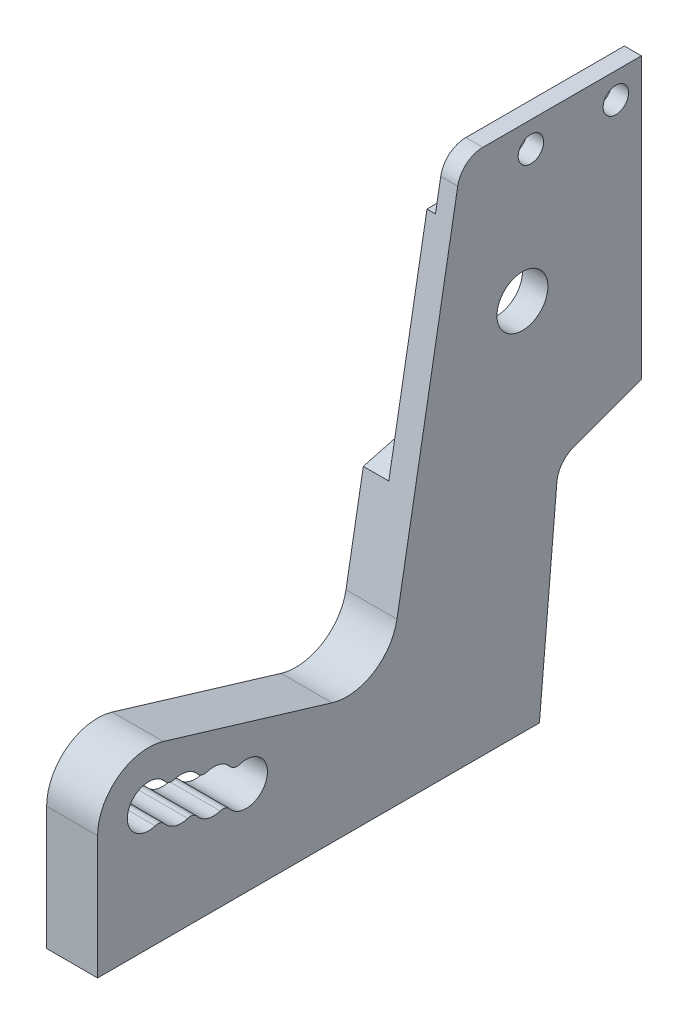
from build123d import *

# Parameters (mm, degrees)
SKETCH1_W                   = 64
SKETCH1_H                   = 62
SKETCH1_R                   = 2.5
SKETCH1_R_2                 = 3
BOSS_EXTRUDE1_DEPTH         = 6
CUT_EXTRUDE1_REACH          = 8
CUT_EXTRUDE2_REACH          = 8
FILLET1_R                   = 3
FILLET2_R                   = 3
TAP_DRILL_FOR_M3_TAP1_D     = 2.5
TAP_DRILL_FOR_M3_TAP1_DEPTH = 9
TAP_DRILL_FOR_M3_TAP1_TIP   = 0.751075774
CUT_EXTRUDE3_DEPTH          = 3
CUT_EXTRUDE4_REACH          = 5
SKETCH10_R                  = 1.5
SKETCH11_R                  = 2.5
CUT_EXTRUDE5_DEPTH          = 6
LPATTERN1_COUNT             = 3
LPATTERN1_PITCH             = 4
FILLET3_R                   = 1
SKETCH12_W                  = 22.982575198
SKETCH12_H                  = 6
CUT_EXTRUDE6_DEPTH          = 1


with BuildPart() as part:
    # Sketch1 → Boss-Extrude1 (new body)
    with BuildSketch(Plane(origin=(0, 0, 0), x_dir=(0, 0, -1), z_dir=(1, 0, 0))):
        with Locations((32, 31)):
            Rectangle(SKETCH1_W, SKETCH1_H)
        with Locations((6, 14.5)):
            Circle(SKETCH1_R, mode=Mode.SUBTRACT)
        with Locations((50, 44)):
            Circle(SKETCH1_R_2, mode=Mode.SUBTRACT)
    extrude(amount=BOSS_EXTRUDE1_DEPTH)

    # Sketch2 → Cut-Extrude1 (cut, up to next)
    with BuildSketch(Plane(origin=(6, 0, 0), x_dir=(0, 0, -1), z_dir=(1, 0, 0)), mode=Mode.PRIVATE) as cut_extrude1_sk1:
        with BuildLine():
            Line((7.732242893, 20.244504727), (27.593137265, 14.255495273))
            ThreePointArc((27.593137265, 14.255495273), (32.470162023, 14.890171527), (35.234226676, 18.958110934))
            Line((35.234226676, 18.958110934), (43, 63))
            Line((43, 63), (0, 63))
            Line((0, 63), (0, 14.5))
            ThreePointArc((0, 14.5), (2.421834084, 19.316298234), (7.732242893, 20.244504727))
        make_face()
    cut_extrude1_tool1 = extrude(cut_extrude1_sk1.sketch, amount=-CUT_EXTRUDE1_REACH, mode=Mode.PRIVATE) & part.part
    add(cut_extrude1_tool1.solids().sort_by_distance((6, 40.863189, -19.912877))[0], mode=Mode.SUBTRACT)

    # Sketch3 → Cut-Extrude2 (cut, up to next)
    with BuildSketch(Plane(origin=(6, 0, 0), x_dir=(0, 0, -1), z_dir=(1, 0, 0)), mode=Mode.PRIVATE) as cut_extrude2_sk1:
        Polygon((64, 0), (52, 0), (54.225932994, 25.442530542), (64, 29), align=None)
    cut_extrude2_tool1 = extrude(cut_extrude2_sk1.sketch, amount=-CUT_EXTRUDE2_REACH, mode=Mode.PRIVATE) & part.part
    add(cut_extrude2_tool1.solids().sort_by_distance((6, 13.1347, -58.667711))[0], mode=Mode.SUBTRACT)

    # Fillet1
    fillet1_edges = [part.edges().sort_by_distance(p)[0] for p in [
        (3, 62, -42.823673019),
    ]]
    fillet(fillet1_edges, radius=FILLET1_R)

    # Fillet2
    fillet2_edges = [part.edges().sort_by_distance(p)[0] for p in [
        (3, 25.442530542, -54.225932994),
    ]]
    fillet(fillet2_edges, radius=FILLET2_R)

    # Tap Drill for M3 Tap1
    with Locations(Plane(origin=(0, 0, 0), x_dir=(-1, 0, 0), z_dir=(0, -1, 0))):
        with Locations((-3, 48), (-3, 12)):
            Hole(TAP_DRILL_FOR_M3_TAP1_D / 2, depth=TAP_DRILL_FOR_M3_TAP1_DEPTH)
            with Locations((0, 0, -(TAP_DRILL_FOR_M3_TAP1_DEPTH + TAP_DRILL_FOR_M3_TAP1_TIP / 2))):  # 118° drill point
                Cone(0, TAP_DRILL_FOR_M3_TAP1_D / 2, TAP_DRILL_FOR_M3_TAP1_TIP, mode=Mode.SUBTRACT)

    # Sketch9 → Cut-Extrude3 (cut)
    with BuildSketch(Plane.ZY):
        Polygon((-64, 62), (-64, 35), (-54, 35), (-37.272527114, 30.517887149), (-42.823673019, 62), align=None)
    extrude(amount=-CUT_EXTRUDE3_DEPTH, mode=Mode.SUBTRACT)

    # Sketch10 → Cut-Extrude4 (cut, up to next)
    with BuildSketch(Plane.ZY.offset(-3), mode=Mode.PRIVATE) as cut_extrude4_sk1:
        with Locations((-61, 59)):
            Circle(SKETCH10_R)
    cut_extrude4_tool1 = extrude(cut_extrude4_sk1.sketch, amount=-CUT_EXTRUDE4_REACH, mode=Mode.PRIVATE) & part.part
    add(cut_extrude4_tool1.solids().sort_by_distance((3, 59, -61))[0], mode=Mode.SUBTRACT)
    # Sketch10 → Cut-Extrude4 (cut, up to next)
    with BuildSketch(Plane.ZY.offset(-3), mode=Mode.PRIVATE) as cut_extrude4_sk2:
        with Locations((-51, 59)):
            Circle(SKETCH10_R)
    cut_extrude4_tool2 = extrude(cut_extrude4_sk2.sketch, amount=-CUT_EXTRUDE4_REACH, mode=Mode.PRIVATE) & part.part
    add(cut_extrude4_tool2.solids().sort_by_distance((3, 59, -51))[0], mode=Mode.SUBTRACT)

    # Sketch11 → Cut-Extrude5 (cut)
    with BuildSketch(Plane.ZY):
        with Locations((-9.829669818, 13.345171405)):
            Circle(SKETCH11_R)
    cut_extrude5 = extrude(amount=-CUT_EXTRUDE5_DEPTH, mode=Mode.SUBTRACT)

    # LPattern1: Cut-Extrude5 ×3
    with Locations(*[Vector(0, -0.288707149, -0.957417455) * (i * LPATTERN1_PITCH) for i in range(1, LPATTERN1_COUNT)]):
        add(cut_extrude5, mode=Mode.SUBTRACT)

    # Fillet3
    fillet3_edges = [part.edges().sort_by_distance(p)[0] for p in [
        (3, 15.358711884, -8.347895632),
        (3, 12.486459521, -7.481774186),
        (3, 14.203883289, -12.17756545),
        (3, 11.331630925, -11.311444004),
        (3, 10.17680233, -15.141113822),
        (3, 13.049054694, -16.007235268),
    ]]
    fillet(fillet3_edges, radius=FILLET3_R)

    # Sketch12 → Cut-Extrude6 (cut)
    with BuildSketch(Plane.ZY.offset(-3)):
        with Locations((-52.508712401, 59)):
            Rectangle(SKETCH12_W, SKETCH12_H)
    extrude(amount=-CUT_EXTRUDE6_DEPTH, mode=Mode.SUBTRACT)


solid = part.part
